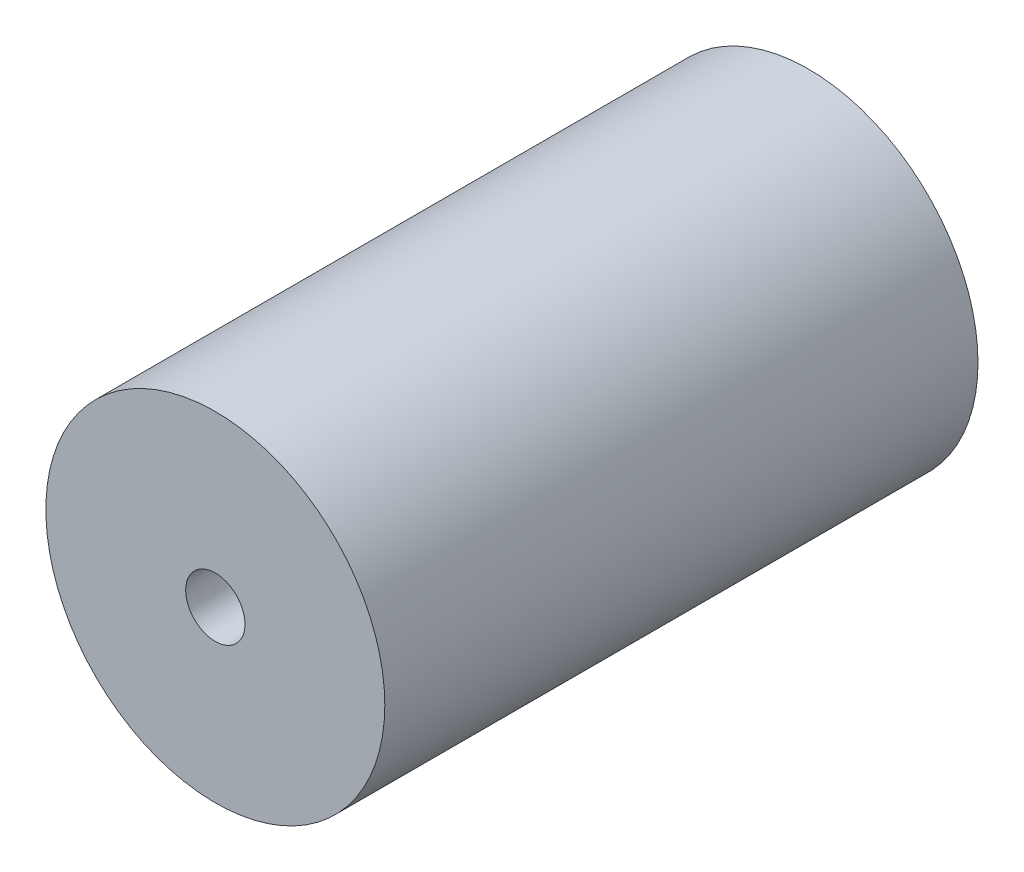
from build123d import *

# Parameters (mm, degrees)
SKETCH2_R               = 100
BOSS_EXTRUDE1_DEPTH     = 175
SKETCH3_R               = 17.5
CUT_EXTRUDE1_DEPTH      = 1
CUT_EXTRUDE1_DEPTH_BACK = 351


with BuildPart() as part:
    # Sketch2 → Boss-Extrude1 (new body, symmetric)
    with BuildSketch(Plane.XY):
        Circle(SKETCH2_R)
    extrude(amount=BOSS_EXTRUDE1_DEPTH, both=True)

    # Sketch3 → Cut-Extrude1 (cut, two sides)
    with BuildSketch(Plane(origin=(0, 0, -175), x_dir=(-1, 0, 0), z_dir=(0, 0, -1))) as cut_extrude1_sk:
        Circle(SKETCH3_R)
    extrude(amount=CUT_EXTRUDE1_DEPTH, mode=Mode.SUBTRACT)
    extrude(cut_extrude1_sk.sketch, amount=-CUT_EXTRUDE1_DEPTH_BACK, mode=Mode.SUBTRACT)


solid = part.part
